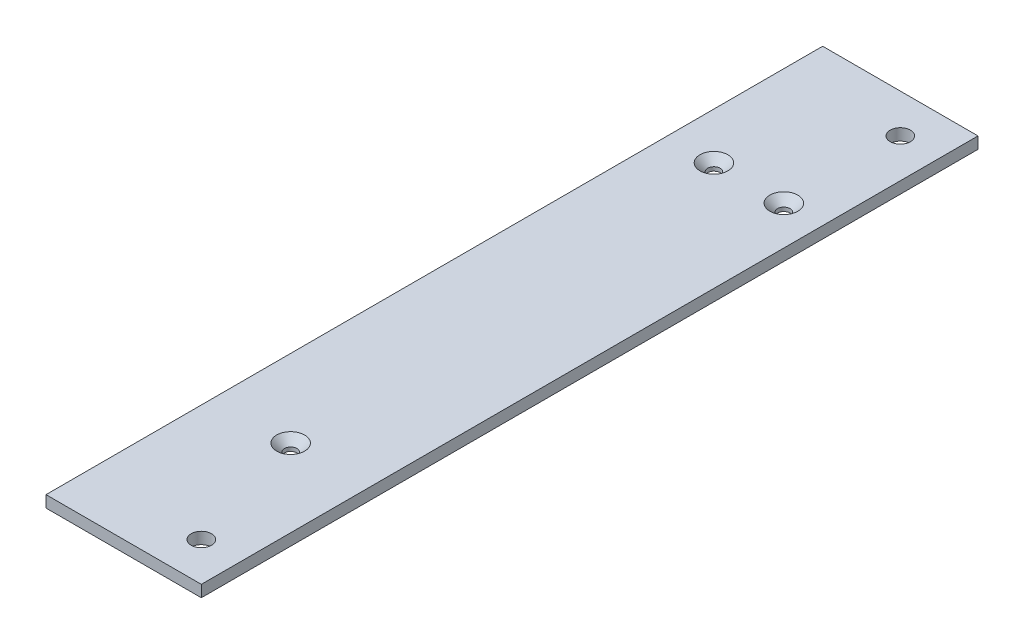
from build123d import *

# Parameters (mm, degrees)
SKETCH1_W           = 40
SKETCH1_H           = 200
SKETCH1_R           = 2.6
SKETCH1_R_2         = 1.6
BOSS_EXTRUDE1_DEPTH = 3
CHAMFER1_SIZE       = 2


with BuildPart() as part:
    # Sketch1 → Boss-Extrude1 (new body)
    with BuildSketch(Plane(origin=(0, 0, 0), x_dir=(1, 0, 0), z_dir=(0, 1, 0))):
        Rectangle(SKETCH1_W, SKETCH1_H)
        with Locations((10, -90)):
            Circle(SKETCH1_R, mode=Mode.SUBTRACT)
        with Locations((10, 90)):
            Circle(SKETCH1_R, mode=Mode.SUBTRACT)
        with Locations((10, 60)):
            Circle(SKETCH1_R_2, mode=Mode.SUBTRACT)
        with Locations((-8, 60)):
            Circle(SKETCH1_R_2, mode=Mode.SUBTRACT)
        with Locations((0, -57)):
            Circle(SKETCH1_R_2, mode=Mode.SUBTRACT)
    extrude(amount=BOSS_EXTRUDE1_DEPTH)

    # Chamfer1
    chamfer1_edges = [part.edges().sort_by_distance(p)[0] for p in [
        (8.4, 3, -60),
        (-9.6, 3, -60),
        (-1.6, 3, 57),
    ]]
    chamfer(chamfer1_edges, length=CHAMFER1_SIZE)


solid = part.part
